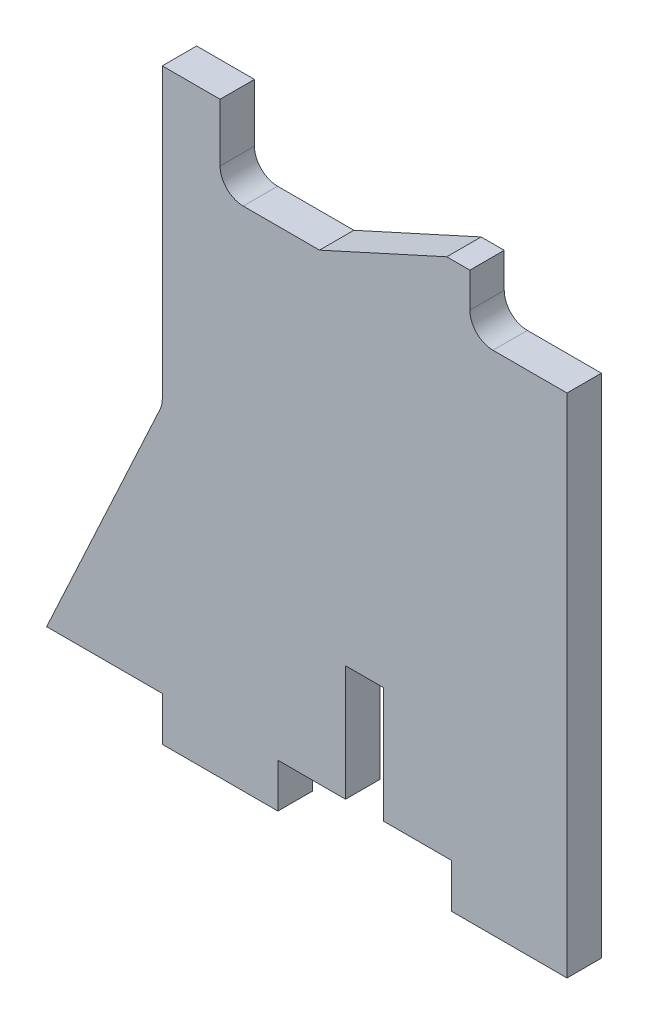
from build123d import *

# Parameters (mm, degrees)
SKETCH1_W           = 35
SKETCH1_H           = 40
BOSS_EXTRUDE1_DEPTH = 2.9718
SKETCH2_W           = 5
SKETCH2_H           = 7
SKETCH2_W_2         = 10
SKETCH2_H_2         = 3.81
BOSS_EXTRUDE2_DEPTH = 2.9718
BOSS_EXTRUDE3_DEPTH = 2.9718
FILLET1_R           = 2
FILLET2_R           = 2
FILLET3_R           = 2
SKETCH4_W           = 3.302
SKETCH4_H           = 10
CUT_EXTRUDE1_DEPTH  = 3.9718


with BuildPart() as part:
    # Sketch1 → Boss-Extrude1 (new body)
    with BuildSketch(Plane.XY):
        Rectangle(SKETCH1_W, SKETCH1_H)
    extrude(amount=BOSS_EXTRUDE1_DEPTH)

    # Sketch2 → Boss-Extrude2 (add)
    with BuildSketch(Plane.XY.offset(2.9718)):
        Polygon((-3.900430119, 20), (7.099569881, 25), (9.099569881, 25), (9.099569881, 20), align=None)
        with Locations((-15, 23.5)):
            Rectangle(SKETCH2_W, SKETCH2_H)
        with Locations((-12.5, -21.905)):
            Rectangle(SKETCH2_W_2, SKETCH2_H_2)
        with Locations((12.5, -21.905)):
            Rectangle(SKETCH2_W_2, SKETCH2_H_2)
    extrude(amount=-BOSS_EXTRUDE2_DEPTH)

    # Sketch3 → Boss-Extrude3 (add)
    with BuildSketch(Plane.XY.offset(2.9718)):
        Polygon((-17.5, -20), (-27.5, -20), (-17.5, 1.595), align=None)
    extrude(amount=-BOSS_EXTRUDE3_DEPTH)

    # Fillet1
    fillet1_edges = [part.edges().sort_by_distance(p)[0] for p in [
        (-12.5, 20, 1.4859),
    ]]
    fillet(fillet1_edges, radius=FILLET1_R)

    # Fillet2
    fillet2_edges = [part.edges().sort_by_distance(p)[0] for p in [
        (9.099569881, 20, 1.4859),
    ]]
    fillet(fillet2_edges, radius=FILLET2_R)

    # Fillet3
    fillet3_edges = [part.edges().sort_by_distance(p)[0] for p in [
        (-17.5, 1.595, 1.4859),
    ]]
    fillet(fillet3_edges, radius=FILLET3_R)

    # Sketch4 → Cut-Extrude1 (cut, through all)
    with BuildSketch(Plane.XY.offset(2.9718)):
        with Locations((0, -15)):
            Rectangle(SKETCH4_W, SKETCH4_H)
    extrude(amount=-CUT_EXTRUDE1_DEPTH, mode=Mode.SUBTRACT)


solid = part.part
